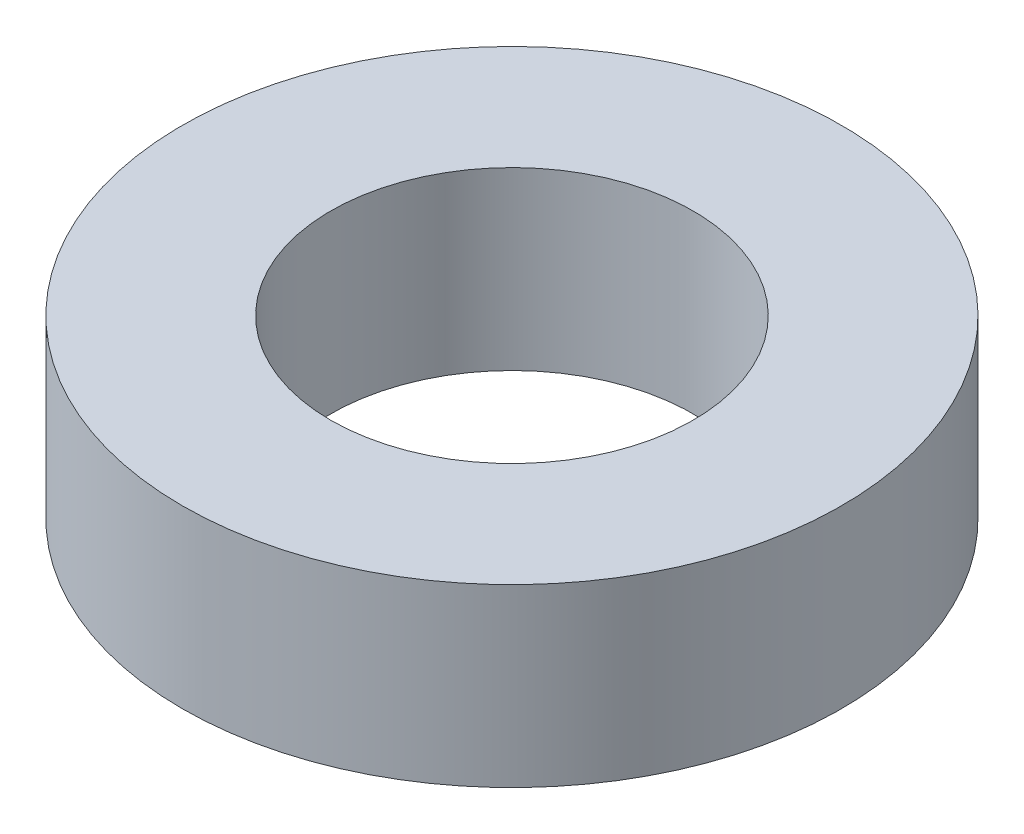
from build123d import *

# Parameters (mm, degrees)
SKETCH1_R           = 3
SKETCH1_R_2         = 1.65
BOSS_EXTRUDE1_DEPTH = 1.6


with BuildPart() as part:
    # Sketch1 → Boss-Extrude1 (new body)
    with BuildSketch(Plane(origin=(0, 0, 0), x_dir=(1, 0, 0), z_dir=(0, 1, 0))):
        Circle(SKETCH1_R)
        Circle(SKETCH1_R_2, mode=Mode.SUBTRACT)
    extrude(amount=BOSS_EXTRUDE1_DEPTH)


solid = part.part
